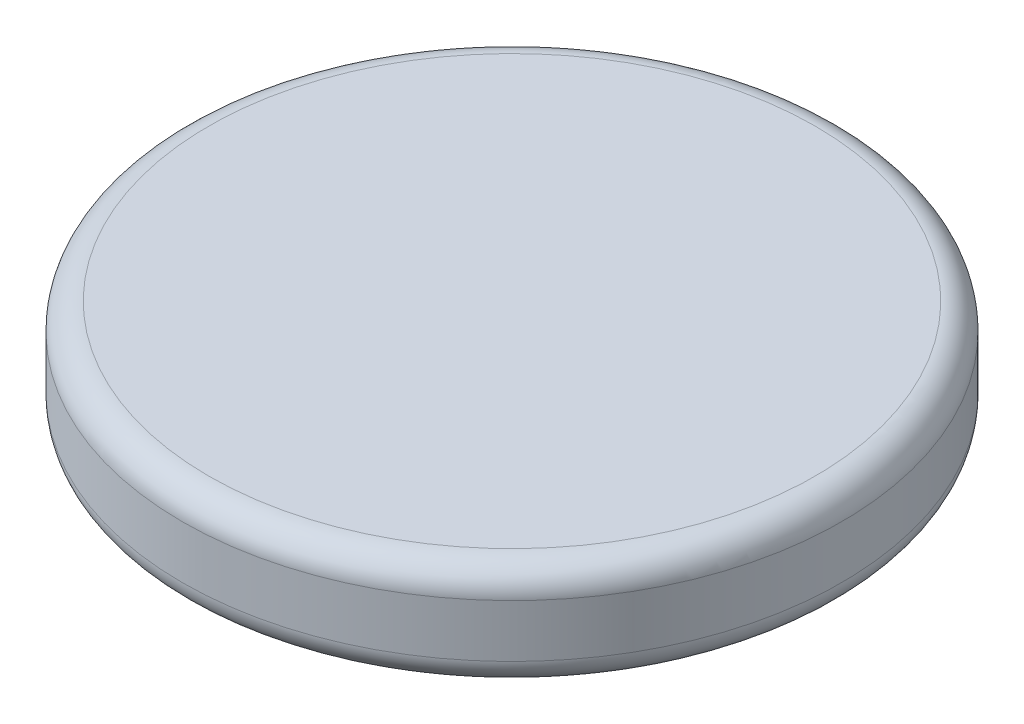
from build123d import *

# Parameters (mm, degrees)
SKETCH_1_R      = 12.5
EXTRUDE_1_DEPTH = 1.2
SKETCH_1_3_R    = 12.5
SKETCH_1_3_R_2  = 11.3
EXTRUDE_2_DEPTH = 4
SKETCH_1_5_W    = 6.2
SKETCH_1_5_H    = 6.2
EXTRUDE_3_DEPTH = 2
EXTRUDE_START   = -2
SKETCH_1_6_W    = 6.2
SKETCH_1_6_H    = 6.2
SKETCH_1_6_W_2  = 3.8
SKETCH_1_6_H_2  = 3.8
EXTRUDE_4_DEPTH = 3
FILLET_1_R      = 1
SKETCH_2_W      = 3.8
SKETCH_2_H      = 3.8
SKETCH_2_W_2    = 3.4
SKETCH_2_H_2    = 3.4
EXTRUDE_5_DEPTH = 0.8


with BuildPart() as part:
    # Sketch 1 → Extrude 1 (new body)
    with BuildSketch(Plane(origin=(0, 0, 0), x_dir=(1, 0, 0), z_dir=(0, 1, 0))):
        Circle(SKETCH_1_R)
    extrude(amount=-EXTRUDE_1_DEPTH)

    # Sketch 1_3 → Extrude 2 (add)
    with BuildSketch(Plane(origin=(0, 0, 0), x_dir=(1, 0, 0), z_dir=(0, 1, 0))):
        Circle(SKETCH_1_3_R)
        Circle(SKETCH_1_3_R_2, mode=Mode.SUBTRACT)
    extrude(amount=-EXTRUDE_2_DEPTH)

    # Sketch 1_5 → Extrude 3 (add)
    with BuildSketch(Plane(origin=(0, 0, 0), x_dir=(1, 0, 0), z_dir=(0, 1, 0))):
        Rectangle(SKETCH_1_5_W, SKETCH_1_5_H)
    extrude(amount=-EXTRUDE_3_DEPTH)

    # Sketch 1_6 → Extrude 4 (add)
    with BuildSketch(Plane(origin=(0, 0, 0), x_dir=(1, 0, 0), z_dir=(0, 1, 0)).offset(EXTRUDE_START)):
        Rectangle(SKETCH_1_6_W, SKETCH_1_6_H)
        Rectangle(SKETCH_1_6_W_2, SKETCH_1_6_H_2, mode=Mode.SUBTRACT)
    extrude(amount=-EXTRUDE_4_DEPTH)

    # Fillet 1
    fillet_1_edges = [part.edges().sort_by_distance(p)[0] for p in [
        (-12.5, 0, 0),
        (-12.5, -4, 0),
    ]]
    fillet(fillet_1_edges, radius=FILLET_1_R)

    # Sketch 2 → Extrude 5 (add)
    with BuildSketch(Plane.XZ.offset(5)):
        Rectangle(SKETCH_2_W, SKETCH_2_H)
        Rectangle(SKETCH_2_W_2, SKETCH_2_H_2, mode=Mode.SUBTRACT)
    extrude(amount=-EXTRUDE_5_DEPTH)


solid = part.part
